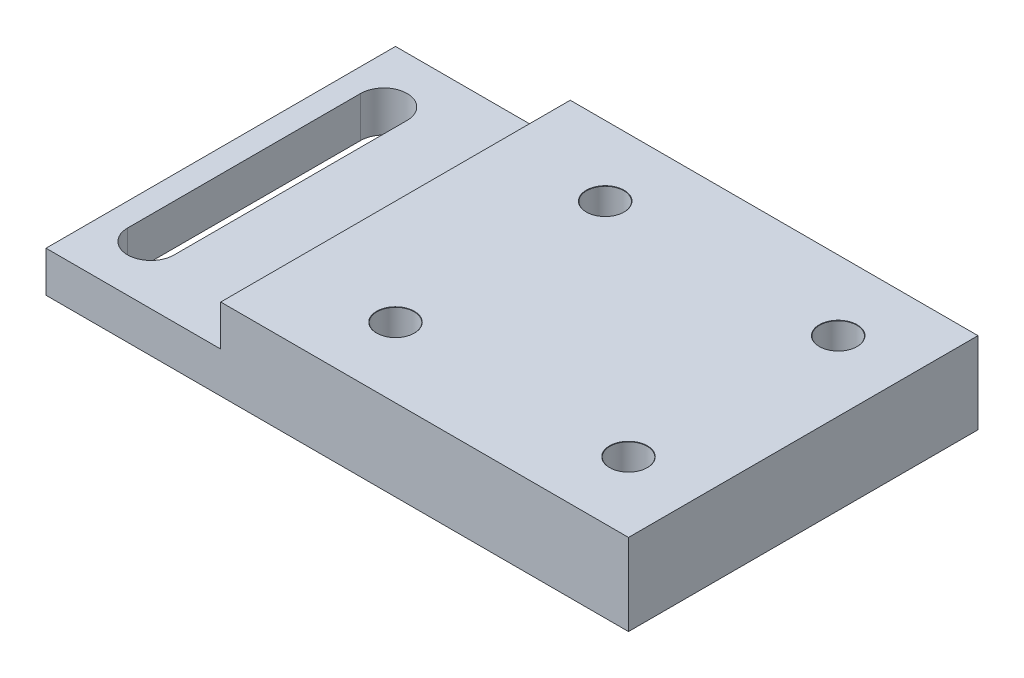
from build123d import *

# Parameters (mm, degrees)
SKETCH1_W                      = 50
SKETCH1_H                      = 30
BOSS_EXTRUDE1_DEPTH            = 7
SKETCH2_W                      = 15
SKETCH2_H                      = 30
CUT_EXTRUDE1_DEPTH             = 3.5
CUT_EXTRUDE2_DEPTH             = 4.5
M3_CLEARANCE_HOLE1_D           = 3.2
M3_CLEARANCE_HOLE1_CSINK_D     = 3.25
M3_CLEARANCE_HOLE1_CSINK_ANGLE = 90


with BuildPart() as part:
    # Sketch1 → Boss-Extrude1 (new body)
    with BuildSketch(Plane(origin=(0, 0, 0), x_dir=(1, 0, 0), z_dir=(0, 1, 0))):
        Rectangle(SKETCH1_W, SKETCH1_H)
    extrude(amount=BOSS_EXTRUDE1_DEPTH)

    # Sketch2 → Cut-Extrude1 (cut)
    with BuildSketch(Plane(origin=(0, 7, 0), x_dir=(1, 0, 0), z_dir=(0, 1, 0))):
        with Locations((-17.5, 0)):
            Rectangle(SKETCH2_W, SKETCH2_H)
    extrude(amount=-CUT_EXTRUDE1_DEPTH, mode=Mode.SUBTRACT)

    # Sketch3 → Cut-Extrude2 (cut, through all)
    with BuildSketch(Plane(origin=(0, 3.5, 0), x_dir=(1, 0, 0), z_dir=(0, 1, 0))):
        with BuildLine():
            Line((-19, 10), (-19, -10))
            ThreePointArc((-19, -10), (-21, -12), (-23, -10))
            Line((-23, -10), (-23, 10))
            ThreePointArc((-23, 10), (-21, 12), (-19, 10))
        make_face()
    extrude(amount=-CUT_EXTRUDE2_DEPTH, mode=Mode.SUBTRACT)

    # M3 Clearance Hole1 (through all)
    with Locations(Plane(origin=(0, 7, 0), x_dir=(1, 0, 0), z_dir=(0, 1, 0))):
        with Locations((-1, 9), (-1, -9), (19, 9), (19, -9)):
            CounterSinkHole(M3_CLEARANCE_HOLE1_D / 2, M3_CLEARANCE_HOLE1_CSINK_D / 2, counter_sink_angle=M3_CLEARANCE_HOLE1_CSINK_ANGLE)


solid = part.part
